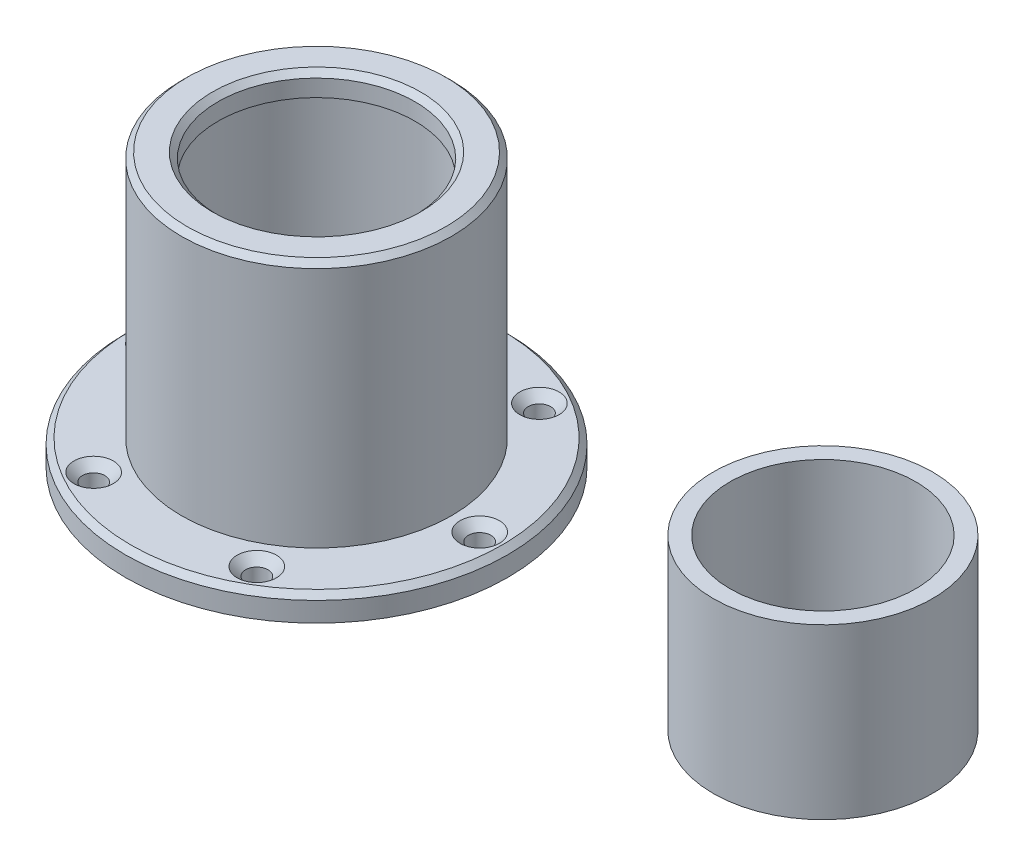
from build123d import *

# Parameters (mm, degrees)
SKETCH1_R                    = 34
SKETCH1_R_2                  = 20
BOSS_EXTRUDE1_DEPTH          = 4.5
SKETCH1_3_R                  = 24
SKETCH1_3_R_2                = 20
BOSS_EXTRUDE2_DEPTH          = 40
SKETCH2_R                    = 24
SKETCH2_R_2                  = 17.5
BOSS_EXTRUDE3_DEPTH          = 4
CHAMFER1_SIZE                = 1
CUT_EXTRUDE1_DEPTH           = 66.176682947
CHAMFER2_SIZE                = 1.5
CIRPATTERN1_COUNT            = 6
CHAMFER2_OF_CIRPATTERN1_SIZE = 1.5
SKETCH4_W                    = 3
SKETCH4_H                    = 3
BOSS_EXTRUDE4_DEPTH          = 3
SKETCH4_3_W                  = 3
SKETCH4_3_H                  = 3
BOSS_EXTRUDE5_DEPTH          = 3
LPATTERN1_COUNT              = 5
LPATTERN1_PITCH              = 6
LPATTERN2_COUNT              = 5
LPATTERN2_PITCH              = 6
LPATTERN3_COUNT              = 5
LPATTERN3_PITCH              = 6
LPATTERN4_COUNT              = 5
LPATTERN4_PITCH              = 6
SKETCH5_R                    = 40
SKETCH5_R_2                  = 19.5
CUT_EXTRUDE5_DEPTH           = 129.188338003
SKETCH6_R                    = 19.5
SKETCH6_R_2                  = 16.5
BOSS_EXTRUDE7_DEPTH          = 30


with BuildPart() as part:
    # Sketch1 → Boss-Extrude1 (new body)
    with BuildSketch(Plane(origin=(0, 0, 0), x_dir=(1, 0, 0), z_dir=(0, 1, 0))):
        with Locations(Location((0, 0, 0), (0, 0, 270))):
            Circle(SKETCH1_R)
        with Locations(Location((0, 0, 0), (0, 0, 270))):
            Circle(SKETCH1_R_2, mode=Mode.SUBTRACT)
    extrude(amount=-BOSS_EXTRUDE1_DEPTH)

    # Sketch1_3 → Boss-Extrude2 (add)
    with BuildSketch(Plane(origin=(0, 0, 0), x_dir=(1, 0, 0), z_dir=(0, 1, 0))):
        with Locations(Location((0, 0, 0), (0, 0, 270))):
            Circle(SKETCH1_3_R)
        with Locations(Location((0, 0, 0), (0, 0, 270))):
            Circle(SKETCH1_3_R_2, mode=Mode.SUBTRACT)
    extrude(amount=BOSS_EXTRUDE2_DEPTH)

    # Sketch2 → Boss-Extrude3 (add)
    with BuildSketch(Plane(origin=(0, 40, 0), x_dir=(1, 0, 0), z_dir=(0, 1, 0))):
        with Locations(Location((0, 0, 0), (0, 0, 270))):
            Circle(SKETCH2_R)
        with Locations(Location((0, 0, 0), (0, 0, 270))):
            Circle(SKETCH2_R_2, mode=Mode.SUBTRACT)
    extrude(amount=BOSS_EXTRUDE3_DEPTH)

    # Chamfer1
    chamfer1_edges = [part.edges().sort_by_distance(p)[0] for p in [
        (0, 44, -24),
        (0, 44, -17.5),
        (0, 0, -34),
    ]]
    chamfer(chamfer1_edges, length=CHAMFER1_SIZE)

    # Sketch1_4 → Cut-Extrude1 (cut, through all)
    with BuildSketch(Plane(origin=(0, 0, 0), x_dir=(1, 0, 0), z_dir=(0, 1, 0))):
        with BuildLine():
            ThreePointArc((27, 0), (29, -2), (31, 0))
            Line((31, 0), (27, 0))
        make_face()
        with BuildLine():
            Line((27, 0), (31, 0))
            ThreePointArc((31, 0), (29, 2), (27, 0))
        make_face()
    cut_extrude1 = extrude(amount=-CUT_EXTRUDE1_DEPTH, mode=Mode.SUBTRACT)

    # Chamfer2
    chamfer2_edges = [part.edges().sort_by_distance(p)[0] for p in [
        (27, 0, 0),
    ]]
    chamfer(chamfer2_edges, length=CHAMFER2_SIZE)

    # CirPattern1: Cut-Extrude1 ×6 about axis
    cirpattern1_axis = Axis((0, 0, 0), (0, 1, 0))
    for i in range(1, CIRPATTERN1_COUNT):
        add(cut_extrude1.rotate(cirpattern1_axis, i * 360 / CIRPATTERN1_COUNT), mode=Mode.SUBTRACT)

    # Chamfer2 of CirPattern1
    chamfer2_of_cirpattern1_edges = [part.edges().sort_by_distance(p)[0] for p in [
        (13.5, 0, -23.382685902),
        (-13.5, 0, -23.382685902),
        (-27, 0, 0),
        (-13.5, 0, 23.382685902),
        (13.5, 0, 23.382685902),
    ]]
    chamfer(chamfer2_of_cirpattern1_edges, length=CHAMFER2_OF_CIRPATTERN1_SIZE)


with BuildPart() as body_2:
    # Sketch4 → Boss-Extrude4 (new body)
    with BuildSketch(Plane(origin=(0, 0, 0), x_dir=(1, 0, 0), z_dir=(0, 1, 0))):
        with BuildLine():
            Line((88.5, -1.5), (88.5, 1.5))
            Line((88.5, 1.5), (73.568323275, 1.5))
            ThreePointArc((73.568323275, 1.5), (73.5, 0), (73.568323275, -1.5))
            Line((73.568323275, -1.5), (88.5, -1.5))
        make_face()
        with BuildLine():
            Line((73.568323275, 1.5), (70.557777905, 1.5))
            ThreePointArc((70.557777905, 1.5), (70.5, 0), (70.557777905, -1.5))
            Line((70.557777905, -1.5), (73.568323275, -1.5))
            ThreePointArc((73.568323275, -1.5), (73.5, 0), (73.568323275, 1.5))
        make_face()
        with BuildLine():
            ThreePointArc((109.5, 0), (109.48555017, 0.750556175), (109.442222095, 1.5))
            Line((109.442222095, 1.5), (106.431676725, 1.5))
            ThreePointArc((106.431676725, 1.5), (106.482910331, 0.750777609), (106.5, 0))
            ThreePointArc((106.5, 0), (106.482910331, -0.750777609), (106.431676725, -1.5))
            Line((106.431676725, -1.5), (109.442222095, -1.5))
            ThreePointArc((109.442222095, -1.5), (109.48555017, -0.750556175), (109.5, 0))
        make_face()
        with BuildLine():
            ThreePointArc((70.056329325, -1.5), (70, 0), (70.056329325, 1.5))
            Line((70.056329325, 1.5), (65, 1.5))
            Line((65, 1.5), (65, -1.5))
            Line((65, -1.5), (70.056329325, -1.5))
        make_face()
        with BuildLine():
            Line((70.557777905, 1.5), (70.056329325, 1.5))
            ThreePointArc((70.056329325, 1.5), (70, 0), (70.056329325, -1.5))
            Line((70.056329325, -1.5), (70.557777905, -1.5))
            ThreePointArc((70.557777905, -1.5), (70.5, 0), (70.557777905, 1.5))
        make_face()
        with BuildLine():
            ThreePointArc((110, 0), (109.985912707, 0.750528646), (109.943670675, 1.5))
            Line((109.943670675, 1.5), (109.442222095, 1.5))
            ThreePointArc((109.442222095, 1.5), (109.48555017, 0.750556175), (109.5, 0))
            ThreePointArc((109.5, 0), (109.48555017, -0.750556175), (109.442222095, -1.5))
            Line((109.442222095, -1.5), (109.943670675, -1.5))
            ThreePointArc((109.943670675, -1.5), (109.985912707, -0.750528646), (110, 0))
        make_face()
        with Locations((90, 0)):
            Rectangle(SKETCH4_W, SKETCH4_H)
        with BuildLine():
            Line((106.431676725, 1.5), (91.5, 1.5))
            Line((91.5, 1.5), (91.5, -1.5))
            Line((91.5, -1.5), (106.431676725, -1.5))
            ThreePointArc((106.431676725, -1.5), (106.482910331, -0.750777609), (106.5, 0))
            ThreePointArc((106.5, 0), (106.482910331, 0.750777609), (106.431676725, 1.5))
        make_face()
        with BuildLine():
            Line((115, 1.5), (109.943670675, 1.5))
            ThreePointArc((109.943670675, 1.5), (109.985912707, 0.750528646), (110, 0))
            ThreePointArc((110, 0), (109.985912707, -0.750528646), (109.943670675, -1.5))
            Line((109.943670675, -1.5), (115, -1.5))
            Line((115, -1.5), (115, 1.5))
        make_face()
    boss_extrude4 = extrude(amount=BOSS_EXTRUDE4_DEPTH)

    # Sketch4_3 → Boss-Extrude5 (add)
    with BuildSketch(Plane(origin=(0, 0, 0), x_dir=(1, 0, 0), z_dir=(0, 1, 0))):
        with BuildLine():
            ThreePointArc((91.5, -19.943670675), (90, -20), (88.5, -19.943670675))
            Line((88.5, -19.943670675), (88.5, -25))
            Line((88.5, -25), (91.5, -25))
            Line((91.5, -25), (91.5, -19.943670675))
        make_face()
        with BuildLine():
            ThreePointArc((91.5, 19.442222095), (90, 19.5), (88.5, 19.442222095))
            Line((88.5, 19.442222095), (88.5, 16.431676725))
            ThreePointArc((88.5, 16.431676725), (90, 16.5), (91.5, 16.431676725))
            Line((91.5, 16.431676725), (91.5, 19.442222095))
        make_face()
        with BuildLine():
            Line((88.5, -16.431676725), (88.5, -19.442222095))
            ThreePointArc((88.5, -19.442222095), (90, -19.5), (91.5, -19.442222095))
            Line((91.5, -19.442222095), (91.5, -16.431676725))
            ThreePointArc((91.5, -16.431676725), (90, -16.5), (88.5, -16.431676725))
        make_face()
        with BuildLine():
            ThreePointArc((91.5, 19.943670675), (90, 20), (88.5, 19.943670675))
            Line((88.5, 19.943670675), (88.5, 19.442222095))
            ThreePointArc((88.5, 19.442222095), (90, 19.5), (91.5, 19.442222095))
            Line((91.5, 19.442222095), (91.5, 19.943670675))
        make_face()
        with BuildLine():
            Line((88.5, -19.442222095), (88.5, -19.943670675))
            ThreePointArc((88.5, -19.943670675), (90, -20), (91.5, -19.943670675))
            Line((91.5, -19.943670675), (91.5, -19.442222095))
            ThreePointArc((91.5, -19.442222095), (90, -19.5), (88.5, -19.442222095))
        make_face()
        with BuildLine():
            Line((91.5, -1.5), (88.5, -1.5))
            Line((88.5, -1.5), (88.5, -16.431676725))
            ThreePointArc((88.5, -16.431676725), (90, -16.5), (91.5, -16.431676725))
            Line((91.5, -16.431676725), (91.5, -1.5))
        make_face()
        with BuildLine():
            ThreePointArc((91.5, 16.431676725), (90, 16.5), (88.5, 16.431676725))
            Line((88.5, 16.431676725), (88.5, 1.5))
            Line((88.5, 1.5), (91.5, 1.5))
            Line((91.5, 1.5), (91.5, 16.431676725))
        make_face()
        with BuildLine():
            Line((91.5, 25), (88.5, 25))
            Line((88.5, 25), (88.5, 19.943670675))
            ThreePointArc((88.5, 19.943670675), (90, 20), (91.5, 19.943670675))
            Line((91.5, 19.943670675), (91.5, 25))
        make_face()
        with Locations((90, 0)):
            Rectangle(SKETCH4_3_W, SKETCH4_3_H)
    boss_extrude5 = extrude(amount=BOSS_EXTRUDE5_DEPTH)

    # LPattern1: Boss-Extrude5 ×5
    with Locations(*[(i * LPATTERN1_PITCH, 0, 0) for i in range(1, LPATTERN1_COUNT)]):
        add(boss_extrude5)

    # LPattern2: Boss-Extrude5 ×5
    with Locations(*[(-i * LPATTERN2_PITCH, 0, 0) for i in range(1, LPATTERN2_COUNT)]):
        add(boss_extrude5)

    # LPattern3: Boss-Extrude4 ×5
    with Locations(*[(0, 0, i * LPATTERN3_PITCH) for i in range(1, LPATTERN3_COUNT)]):
        add(boss_extrude4)

    # LPattern4: Boss-Extrude4 ×5
    with Locations(*[(0, 0, -i * LPATTERN4_PITCH) for i in range(1, LPATTERN4_COUNT)]):
        add(boss_extrude4)

    # Sketch5 → Cut-Extrude5 (cut, through all)
    with BuildSketch(Plane(origin=(0, 0, 0), x_dir=(1, 0, 0), z_dir=(0, 1, 0))):
        with Locations((90, 0)):
            Circle(SKETCH5_R)
        with Locations((90, 0)):
            Circle(SKETCH5_R_2, mode=Mode.SUBTRACT)
    extrude(amount=CUT_EXTRUDE5_DEPTH, mode=Mode.SUBTRACT)

    # Sketch6 → Boss-Extrude7 (add)
    with BuildSketch(Plane(origin=(0, 0, 0), x_dir=(1, 0, 0), z_dir=(0, 1, 0))):
        with Locations(Location((90, 0, 0), (0, 0, 270))):
            Circle(SKETCH6_R)
        with Locations(Location((90, 0, 0), (0, 0, 95.21590857))):
            Circle(SKETCH6_R_2, mode=Mode.SUBTRACT)
    extrude(amount=BOSS_EXTRUDE7_DEPTH)


solid = Compound([part.part, body_2.part])
